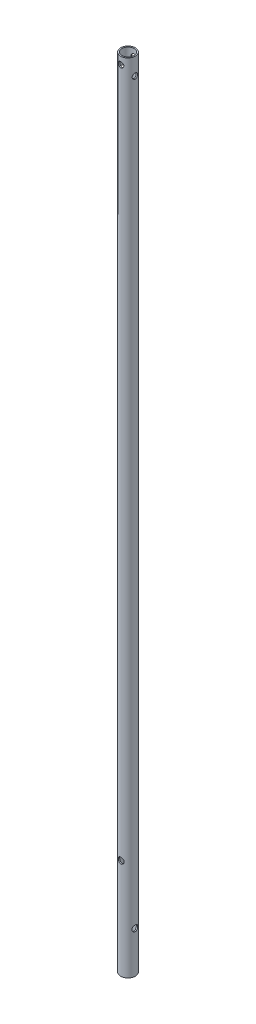
from build123d import *

# Parameters (mm, degrees)
SKETCH_2_R               = 15
SKETCH_2_R_2             = 12.5
EXTRUDE_1_DEPTH          = 1630
SKETCH_3_R               = 5.5
CUT_EXTRUDE_1_DEPTH      = 16
CUT_EXTRUDE_1_DEPTH_BACK = 16
SKETCH_4_R               = 5.5
CUT_EXTRUDE_2_DEPTH      = 16.0000001
CUT_EXTRUDE_2_DEPTH_BACK = 16.0000001
SKETCH_5_R               = 6
CUT_EXTRUDE_3_DEPTH      = 16.0000001
CUT_EXTRUDE_3_DEPTH_BACK = 16.0000001
SKETCH_6_R               = 6
CUT_EXTRUDE_4_DEPTH      = 16.0000001
CUT_EXTRUDE_4_DEPTH_BACK = 16.0000001


with BuildPart() as part:
    # Эскиз2 → Бобышка-Вытянуть1 (new body)
    with BuildSketch(Plane(origin=(0, 0, 0), x_dir=(1, 0, 0), z_dir=(0, 1, 0))):
        Circle(SKETCH_2_R)
        Circle(SKETCH_2_R_2, mode=Mode.SUBTRACT)
    extrude(amount=EXTRUDE_1_DEPTH)

    # Эскиз3 → Вырез-Вытянуть1 (cut, two sides)
    with BuildSketch(Plane.XY) as cut_extrude_1_sk:
        with Locations((0, 1615)):
            Circle(SKETCH_3_R)
    extrude(amount=CUT_EXTRUDE_1_DEPTH, mode=Mode.SUBTRACT)
    extrude(cut_extrude_1_sk.sketch, amount=-CUT_EXTRUDE_1_DEPTH_BACK, mode=Mode.SUBTRACT)

    # Эскиз4 → Вырез-Вытянуть2 (cut, two sides)
    with BuildSketch(Plane(origin=(0, 0, 0), x_dir=(0, 0, -1), z_dir=(1, 0, 0))) as cut_extrude_2_sk:
        with Locations((0, 1595)):
            Circle(SKETCH_4_R)
    extrude(amount=CUT_EXTRUDE_2_DEPTH, mode=Mode.SUBTRACT)
    extrude(cut_extrude_2_sk.sketch, amount=-CUT_EXTRUDE_2_DEPTH_BACK, mode=Mode.SUBTRACT)

    # Эскиз5 → Вырез-Вытянуть3 (cut, two sides)
    with BuildSketch(Plane.XY) as cut_extrude_3_sk:
        with Locations((0, 205)):
            Circle(SKETCH_5_R)
    extrude(amount=CUT_EXTRUDE_3_DEPTH, mode=Mode.SUBTRACT)
    extrude(cut_extrude_3_sk.sketch, amount=-CUT_EXTRUDE_3_DEPTH_BACK, mode=Mode.SUBTRACT)

    # Эскиз6 → Вырез-Вытянуть4 (cut, two sides)
    with BuildSketch(Plane(origin=(0, 0, 0), x_dir=(0, 0, -1), z_dir=(1, 0, 0))) as cut_extrude_4_sk:
        with Locations((0, 85)):
            Circle(SKETCH_6_R)
    extrude(amount=CUT_EXTRUDE_4_DEPTH, mode=Mode.SUBTRACT)
    extrude(cut_extrude_4_sk.sketch, amount=-CUT_EXTRUDE_4_DEPTH_BACK, mode=Mode.SUBTRACT)


solid = part.part
